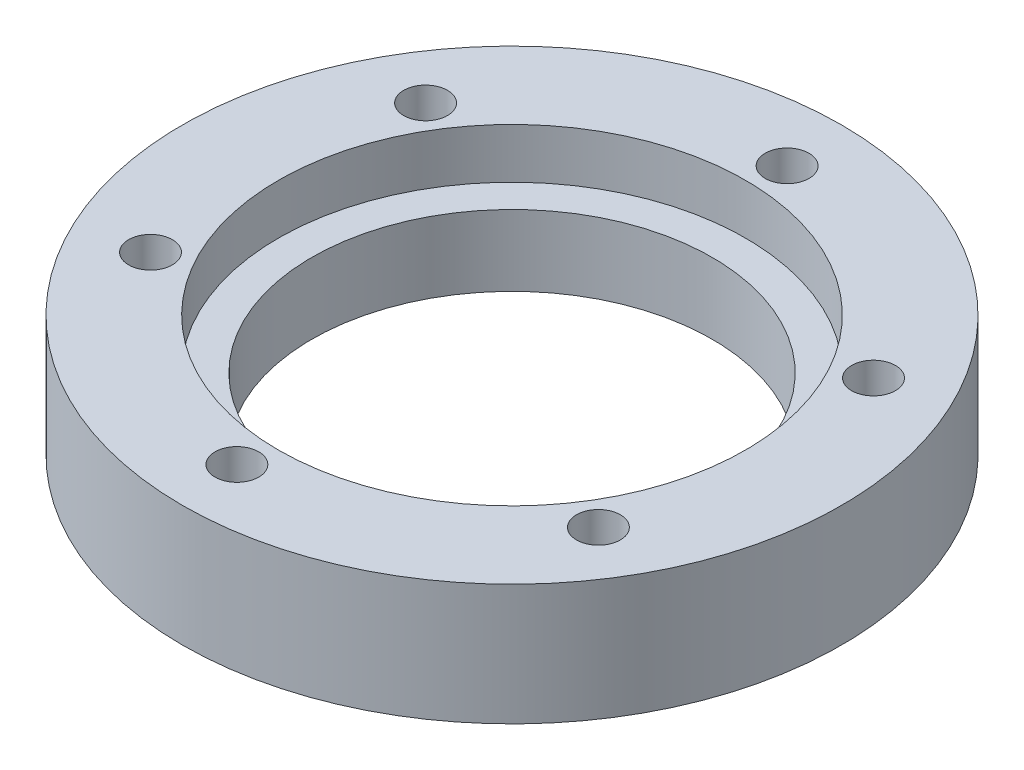
from build123d import *

# Parameters (mm, degrees)
SKETCH1_R                                           = 79
BOSS_EXTRUDE1_DEPTH                                 = 29
CBORE_FOR_00_BINDING_HEAD_MACHINE_SCREW_D           = 96.000000024
CBORE_FOR_00_BINDING_HEAD_MACHINE_SCREW_CBORE_D     = 112.000000028
CBORE_FOR_00_BINDING_HEAD_MACHINE_SCREW_CBORE_DEPTH = 11.999999876
TAP_DRILL_FOR_M12X1_5_TAP2_D                        = 10.5


with BuildPart() as part:
    # Sketch1 → Boss-Extrude1 (new body)
    with BuildSketch(Plane(origin=(0, 0, 0), x_dir=(1, 0, 0), z_dir=(0, 1, 0))):
        Circle(SKETCH1_R)
    extrude(amount=BOSS_EXTRUDE1_DEPTH)

    # CBORE for #00 Binding Head Machine Screw1 (through all)
    with Locations(Plane(origin=(0, 29, 0), x_dir=(1, 0, 0), z_dir=(0, 1, 0))):
        with Locations((0, 0)):
            CounterBoreHole(CBORE_FOR_00_BINDING_HEAD_MACHINE_SCREW_D / 2, CBORE_FOR_00_BINDING_HEAD_MACHINE_SCREW_CBORE_D / 2, CBORE_FOR_00_BINDING_HEAD_MACHINE_SCREW_CBORE_DEPTH)

    # Tap Drill for M12x1.5 Tap2 (through all)
    with Locations(Plane(origin=(0, 29, 0), x_dir=(1, 0, 0), z_dir=(0, 1, 0))):
        with Locations((54.411006739, -33.696325403), (-1.976370444, -63.969476783), (-56.387377183, -30.27315138), (-54.411006739, 33.696325403), (1.976370444, 63.969476783), (56.387377183, 30.27315138), (0, 0)):
            Hole(TAP_DRILL_FOR_M12X1_5_TAP2_D / 2)


solid = part.part
